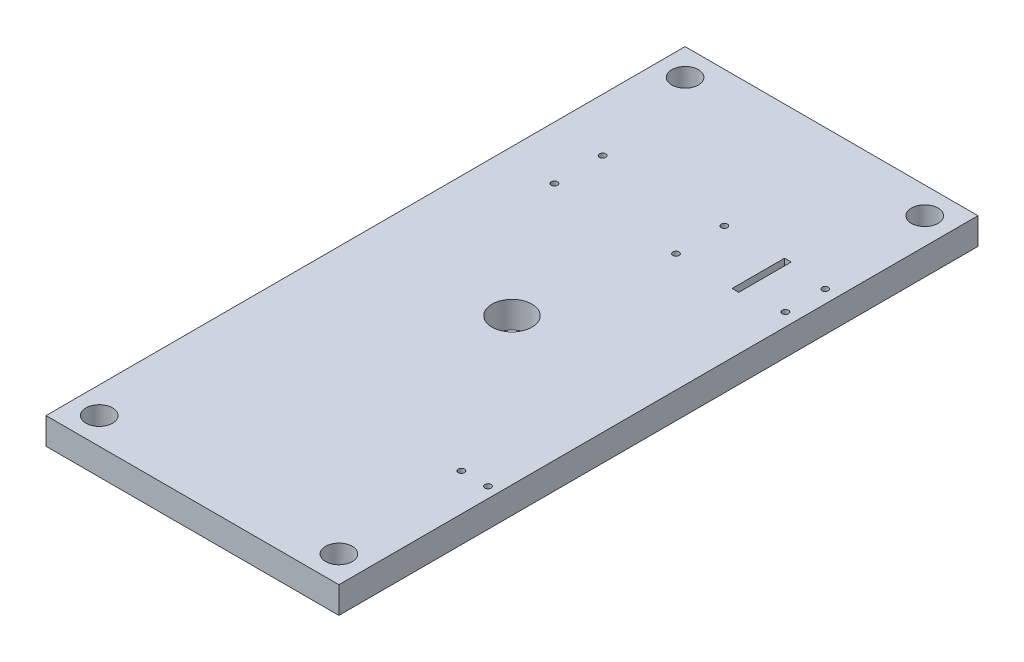
from build123d import *

# Parameters (mm, degrees)
SKETCH1_W                      = 139.7
SKETCH1_H                      = 304.8
BOSS_EXTRUDE1_DEPTH            = 12.7
SKETCH5_R                      = 6.35
CUT_EXTRUDE2_DEPTH             = 13.7
F_3_4_0_7500_DOWEL_HOLE1_D     = 19.05
F_3_4_0_7500_DOWEL_HOLE1_DEPTH = 25.4
F_3_4_0_7500_DOWEL_HOLE1_TIP   = 5.723197396
SKETCH10_R                     = 1.5
CUT_EXTRUDE3_DEPTH             = 13.7
SKETCH11_R                     = 1.5
CUT_EXTRUDE4_DEPTH             = 13.7
SKETCH12_R                     = 1.5
SKETCH12_W                     = 3.175
SKETCH12_H                     = 25
CUT_EXTRUDE6_DEPTH             = 13.7


with BuildPart() as part:
    # Sketch1 → Boss-Extrude1 (new body)
    with BuildSketch(Plane(origin=(0, 0, 0), x_dir=(1, 0, 0), z_dir=(0, 1, 0))):
        with Locations((69.85, 152.4)):
            Rectangle(SKETCH1_W, SKETCH1_H)
    extrude(amount=BOSS_EXTRUDE1_DEPTH)

    # Sketch5 → Cut-Extrude2 (cut, through all)
    with BuildSketch(Plane(origin=(0, 12.7, 0), x_dir=(1, 0, 0), z_dir=(0, 1, 0))):
        with Locations((12.7, 12.7)):
            Circle(SKETCH5_R)
        with Locations((127, 12.7)):
            Circle(SKETCH5_R)
        with Locations((127, 292.1)):
            Circle(SKETCH5_R)
        with Locations((12.7, 292.1)):
            Circle(SKETCH5_R)
    extrude(amount=-CUT_EXTRUDE2_DEPTH, mode=Mode.SUBTRACT)

    # 3/4 (0.7500) Dowel Hole1
    with Locations(Plane(origin=(69.85, 12.7, -152.4), x_dir=(0, 0, 1), z_dir=(0, 1, 0))):
        with Locations((0, 0)):
            Hole(F_3_4_0_7500_DOWEL_HOLE1_D / 2, depth=F_3_4_0_7500_DOWEL_HOLE1_DEPTH)
            with Locations((0, 0, -(F_3_4_0_7500_DOWEL_HOLE1_DEPTH + F_3_4_0_7500_DOWEL_HOLE1_TIP / 2))):  # 118° drill point
                Cone(0, F_3_4_0_7500_DOWEL_HOLE1_D / 2, F_3_4_0_7500_DOWEL_HOLE1_TIP, mode=Mode.SUBTRACT)

    # Sketch10 → Cut-Extrude3 (cut, through all)
    with BuildSketch(Plane(origin=(0, 12.7, 0), x_dir=(1, 0, 0), z_dir=(0, 1, 0))):
        with Locations((25.4, 217.0999976)):
            Circle(SKETCH10_R)
        with Locations((25.4, 240.1000024)):
            Circle(SKETCH10_R)
        with Locations((83.400011, 240.1000024)):
            Circle(SKETCH10_R)
        with Locations((83.400011, 217.0999976)):
            Circle(SKETCH10_R)
    extrude(amount=-CUT_EXTRUDE3_DEPTH, mode=Mode.SUBTRACT)

    # Sketch11 → Cut-Extrude4 (cut, through all)
    with BuildSketch(Plane(origin=(0, 12.7, 0), x_dir=(1, 0, 0), z_dir=(0, 1, 0))):
        with Locations((134.62, 76.2)):
            Circle(SKETCH11_R)
        with Locations((121.92, 76.2)):
            Circle(SKETCH11_R)
    extrude(amount=-CUT_EXTRUDE4_DEPTH, mode=Mode.SUBTRACT)

    # Sketch12 → Cut-Extrude6 (cut, through all)
    with BuildSketch(Plane(origin=(0, 12.7, 0), x_dir=(1, 0, 0), z_dir=(0, 1, 0))):
        with Locations((133.52, 219.09999995)):
            Circle(SKETCH12_R)
        with Locations((133.52, 238.10000005)):
            Circle(SKETCH12_R)
        with Locations((112.7125, 228.6)):
            Rectangle(SKETCH12_W, SKETCH12_H)
    extrude(amount=-CUT_EXTRUDE6_DEPTH, mode=Mode.SUBTRACT)


solid = part.part
